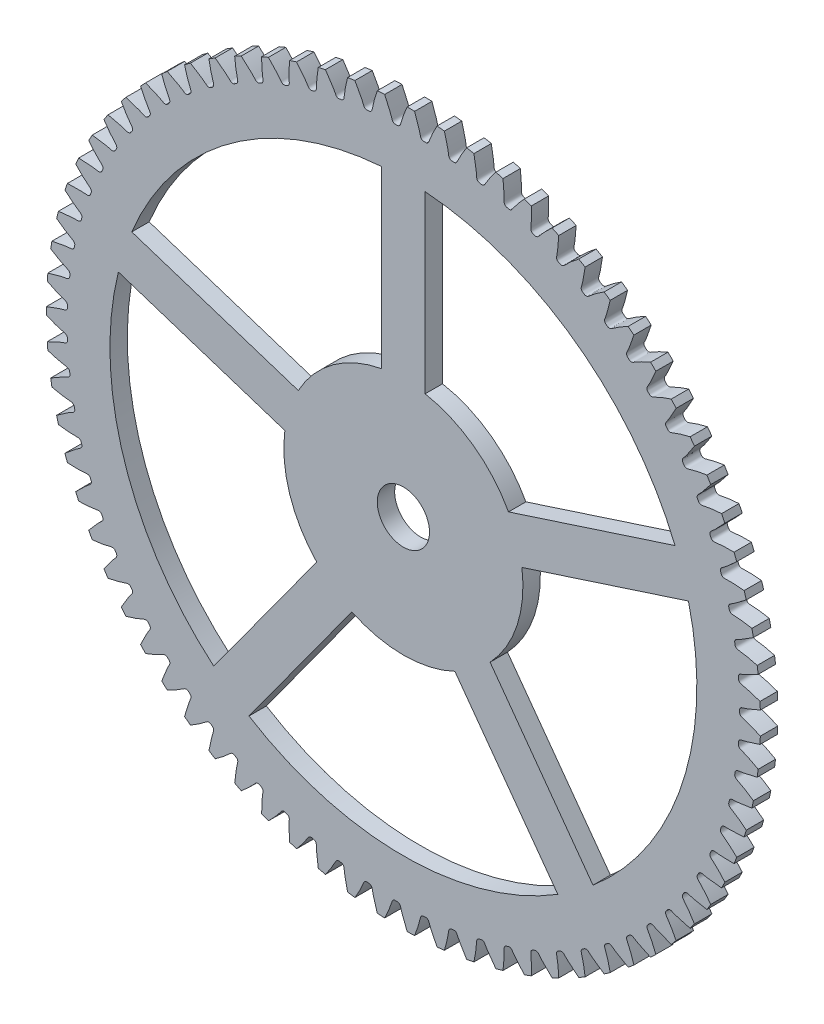
from build123d import *

# Parameters (mm, degrees)
SKETCHREVOLVEENGRANAJE_ABAJO_8_2_W       = 0.2
SKETCHREVOLVEENGRANAJE_ABAJO_8_2_H       = 4.106666667
TOOTHEXTRUDECUTENGRANAJE_ABAJO_8_2_DEPTH = 0.1
PATTERNENGRANAJE_ABAJO_8_2_COUNT         = 75
CORTAR_EXTRUIR2_REACH                    = 7.811
CROQUIS5_R                               = 0.3


with BuildPart() as part:
    # SketchRevolveEngranaje Abajo_8.2 → Engranaje Abajo_8.2 (revolve)
    with BuildSketch(Plane(origin=(0, 0, 0), x_dir=(0, 0, -1), z_dir=(1, 0, 0))):
        with Locations((0, 2.053333333)):
            Rectangle(SKETCHREVOLVEENGRANAJE_ABAJO_8_2_W, SKETCHREVOLVEENGRANAJE_ABAJO_8_2_H)
    revolve(axis=Axis((0, 0, 0), (0, 0, -1)))

    # SketchToothEngranaje Abajo_8.2 → ToothExtrudeCutEngranaje Abajo_8.2 (cut, symmetric)
    with BuildSketch(Plane.XY):
        with BuildLine():
            ThreePointArc((4.109878943, 0.132057094), (4.112, 0), (4.109878943, -0.132057094))
            add(Edge.make_bspline(
                [(4.109878943, -0.132057094), (4.097004103, -0.125843702), (4.079908863, -0.117862328), (4.058588482, -0.108373055), (4.046284915, -0.103026742), (4.034204868, -0.097903976), (4.022351312, -0.093000382), (4.010727157, -0.088311545), (3.999335248, -0.083833027), (3.988178383, -0.079560321), (3.977259259, -0.07548901), (3.966580642, -0.071614207), (3.956144782, -0.067932571), (3.945955487, -0.064435069), (3.936010698, -0.061132917), (3.92632907, -0.057964739), (3.915799697, -0.05481262), (3.907884498, -0.051909257), (3.90212185, -0.050570949), (3.899798804, -0.04992693), (3.897501932, -0.049231129), (3.895219298, -0.048457967), (3.892931124, -0.047593413), (3.890614675, -0.046611637), (3.888242305, -0.045477305), (3.885782115, -0.044139048), (3.883199948, -0.042522752), (3.880465956, -0.040522053), (3.87757013, -0.037988529), (3.874554796, -0.03472892), (3.871564835, -0.030528113), (3.868915369, -0.025230101), (3.867084359, -0.019047994), (3.866397929, -0.010476562), (3.866841982, 0), (3.866397929, 0.010476562), (3.867084359, 0.019047994), (3.868915369, 0.025230101), (3.871564835, 0.030528113), (3.874554796, 0.03472892), (3.87757013, 0.037988529), (3.880465956, 0.040522053), (3.883199948, 0.042522752), (3.885782115, 0.044139048), (3.888242305, 0.045477305), (3.890614675, 0.046611637), (3.892931124, 0.047593413), (3.895219298, 0.048457967), (3.897501932, 0.049231129), (3.899798804, 0.04992693), (3.90212185, 0.050570949), (3.907884498, 0.051909257), (3.915799697, 0.05481262), (3.92632907, 0.057964739), (3.936010698, 0.061132917), (3.945955487, 0.064435069), (3.956144782, 0.067932571), (3.966580642, 0.071614207), (3.977259259, 0.07548901), (3.988178383, 0.079560321), (3.999335248, 0.083833027), (4.010727157, 0.088311545), (4.022351312, 0.093000382), (4.034204868, 0.097903976), (4.046284915, 0.103026742), (4.058588482, 0.108373055), (4.079908863, 0.117862328), (4.097004103, 0.125843702), (4.109878943, 0.132057094)],
                knots=[0, 0, 0, 0, 0.073384251, 0.096841121, 0.119795637, 0.142247799, 0.164197606, 0.18564506, 0.206590159, 0.227032904, 0.246973296, 0.266411333, 0.285347016, 0.303780345, 0.32171132, 0.339139941, 0.356066208, 0.378145812, 0.382308663, 0.386423939, 0.390518728, 0.39462724, 0.398793113, 0.403072563, 0.40753863, 0.412286765, 0.417441778, 0.423165246, 0.429660094, 0.437163544, 0.44591001, 0.456038699, 0.467444314, 0.478761712, 0.5, 0.521238288, 0.532555686, 0.543961301, 0.55408999, 0.562836456, 0.570339906, 0.576834754, 0.582558222, 0.587713235, 0.59246137, 0.596927437, 0.601206887, 0.60537276, 0.609481272, 0.613576061, 0.617691337, 0.621854188, 0.643933792, 0.660860059, 0.67828868, 0.696219655, 0.714652984, 0.733588667, 0.753026704, 0.772967096, 0.793409841, 0.81435494, 0.835802394, 0.857752201, 0.880204363, 0.903158879, 0.926615749, 1, 1, 1, 1], degree=3))
        make_face()
    toothextrudecutengranaje_abajo_8_2 = extrude(amount=TOOTHEXTRUDECUTENGRANAJE_ABAJO_8_2_DEPTH, both=True, mode=Mode.SUBTRACT)

    # PatternEngranaje Abajo_8.2: ToothExtrudeCutEngranaje Abajo_8.2 ×75 about axis
    patternengranaje_abajo_8_2_axis = Axis((0, 0, 55), (0, 0, -1))
    for i in range(1, PATTERNENGRANAJE_ABAJO_8_2_COUNT):
        add(toothextrudecutengranaje_abajo_8_2.rotate(patternengranaje_abajo_8_2_axis, i * 360 / PATTERNENGRANAJE_ABAJO_8_2_COUNT), mode=Mode.SUBTRACT)

    # Croquis5 → Cortar-Extruir2 (cut, up to next)
    with BuildSketch(Plane.XY.offset(0.1), mode=Mode.PRIVATE) as cortar_extruir2_sk1:
        Circle(CROQUIS5_R)
    cortar_extruir2_tool1 = extrude(cortar_extruir2_sk1.sketch, amount=-CORTAR_EXTRUIR2_REACH, mode=Mode.PRIVATE) & part.part
    # Croquis5 → Cortar-Extruir2 (cut, up to next)
    with BuildSketch(Plane.XY.offset(0.1), mode=Mode.PRIVATE) as cortar_extruir2_sk2:
        with BuildLine():
            Line((1.363160387, 0.180052103), (3.278251799, 0.802303023))
            ThreePointArc((3.278251799, 0.802303023), (3.209815742, -1.042932356), (2.180579533, -2.575984841))
            Line((2.180579533, -2.575984841), (0.996987948, -0.946910783))
            ThreePointArc((0.996987948, -0.946910783), (1.30770271, -0.424898367), (1.363160387, 0.180052103))
        make_face()
    cortar_extruir2_tool2 = extrude(cortar_extruir2_sk2.sketch, amount=-CORTAR_EXTRUIR2_REACH, mode=Mode.PRIVATE) & part.part
    # Croquis5 → Cortar-Extruir2 (cut, up to next)
    with BuildSketch(Plane.XY.offset(0.1), mode=Mode.PRIVATE) as cortar_extruir2_sk3:
        with BuildLine():
            Line((0.592479451, -1.240803409), (1.776071036, -2.869877467))
            ThreePointArc((1.776071036, -2.869877467), (0, -3.375), (-1.776071036, -2.869877467))
            Line((-1.776071036, -2.869877467), (-0.592479451, -1.240803409))
            ThreePointArc((-0.592479451, -1.240803409), (0, -1.375), (0.592479451, -1.240803409))
        make_face()
    cortar_extruir2_tool3 = extrude(cortar_extruir2_sk3.sketch, amount=-CORTAR_EXTRUIR2_REACH, mode=Mode.PRIVATE) & part.part
    # Croquis5 → Cortar-Extruir2 (cut, up to next)
    with BuildSketch(Plane.XY.offset(0.1), mode=Mode.PRIVATE) as cortar_extruir2_sk4:
        with BuildLine():
            Line((-0.996987948, -0.946910783), (-2.180579533, -2.575984841))
            ThreePointArc((-2.180579533, -2.575984841), (-3.209815742, -1.042932356), (-3.278251799, 0.802303023))
            Line((-3.278251799, 0.802303023), (-1.363160387, 0.180052103))
            ThreePointArc((-1.363160387, 0.180052103), (-1.30770271, -0.424898367), (-0.996987948, -0.946910783))
        make_face()
    cortar_extruir2_tool4 = extrude(cortar_extruir2_sk4.sketch, amount=-CORTAR_EXTRUIR2_REACH, mode=Mode.PRIVATE) & part.part
    # Croquis5 → Cortar-Extruir2 (cut, up to next)
    with BuildSketch(Plane.XY.offset(0.1), mode=Mode.PRIVATE) as cortar_extruir2_sk5:
        with BuildLine():
            Line((-1.20865189, 0.655580361), (-3.123743302, 1.277831281))
            ThreePointArc((-3.123743302, 1.277831281), (-1.983775226, 2.730432356), (-0.25, 3.365728004))
            Line((-0.25, 3.365728004), (-0.25, 1.352081728))
            ThreePointArc((-0.25, 1.352081728), (-0.808204722, 1.112398367), (-1.20865189, 0.655580361))
        make_face()
    cortar_extruir2_tool5 = extrude(cortar_extruir2_sk5.sketch, amount=-CORTAR_EXTRUIR2_REACH, mode=Mode.PRIVATE) & part.part
    # Croquis5 → Cortar-Extruir2 (cut, up to next)
    with BuildSketch(Plane.XY.offset(0.1), mode=Mode.PRIVATE) as cortar_extruir2_sk6:
        with BuildLine():
            Line((0.25, 1.352081728), (0.25, 3.365728004))
            ThreePointArc((0.25, 3.365728004), (1.983775226, 2.730432356), (3.123743302, 1.277831281))
            Line((3.123743302, 1.277831281), (1.20865189, 0.655580361))
            ThreePointArc((1.20865189, 0.655580361), (0.808204722, 1.112398367), (0.25, 1.352081728))
        make_face()
    cortar_extruir2_tool6 = extrude(cortar_extruir2_sk6.sketch, amount=-CORTAR_EXTRUIR2_REACH, mode=Mode.PRIVATE) & part.part
    add(cortar_extruir2_tool1.solids().sort_by_distance((0, 0, 0.1))[0], mode=Mode.SUBTRACT)
    add(cortar_extruir2_tool2.solids().sort_by_distance((2.307476, -0.749744, 0.1))[0], mode=Mode.SUBTRACT)
    add(cortar_extruir2_tool3.solids().sort_by_distance((0, -2.426224, 0.1))[0], mode=Mode.SUBTRACT)
    add(cortar_extruir2_tool4.solids().sort_by_distance((-2.307476, -0.749744, 0.1))[0], mode=Mode.SUBTRACT)
    add(cortar_extruir2_tool5.solids().sort_by_distance((-1.426099, 1.962856, 0.1))[0], mode=Mode.SUBTRACT)
    add(cortar_extruir2_tool6.solids().sort_by_distance((1.426099, 1.962856, 0.1))[0], mode=Mode.SUBTRACT)


solid = part.part
